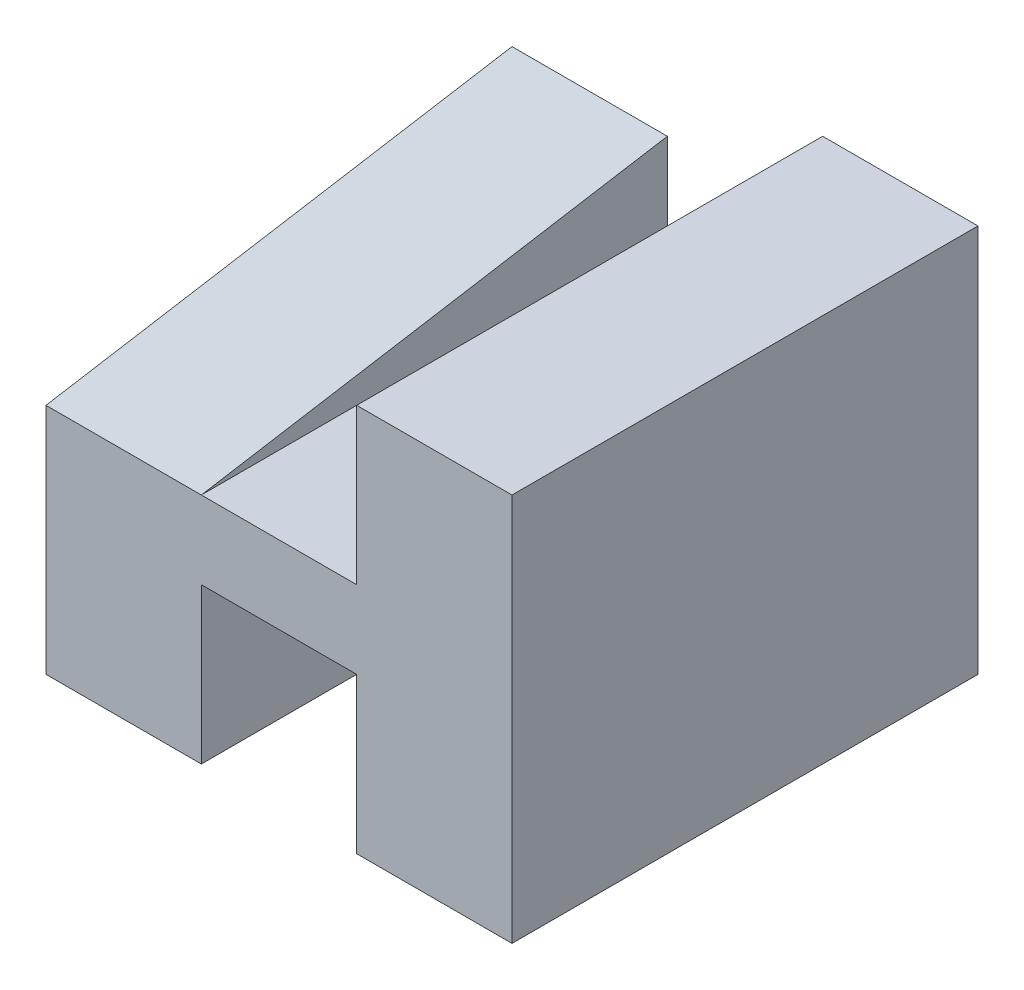
from build123d import *

# Parameters (mm, degrees)
SKETCH1_W           = 6
SKETCH1_H           = 6
BOSS_EXTRUDE1_DEPTH = 5
SKETCH2_W           = 6
SKETCH2_H           = 2
CUT_EXTRUDE1_DEPTH  = 1
CUT_EXTRUDE2_DEPTH  = 2


with BuildPart() as part:
    # Sketch1 → Boss-Extrude1 (new body)
    with BuildSketch(Plane(origin=(0, 0, 0), x_dir=(1, 0, 0), z_dir=(0, 1, 0))):
        Rectangle(SKETCH1_W, SKETCH1_H)
    extrude(amount=BOSS_EXTRUDE1_DEPTH)

    # Sketch2 → Cut-Extrude1 (cut, symmetric)
    with BuildSketch(Plane(origin=(0, 0, 0), x_dir=(0, 0, -1), z_dir=(1, 0, 0))):
        Polygon((3, 0), (-3, 2), (-3, 0), align=None)
        with Locations((0, 4)):
            Rectangle(SKETCH2_W, SKETCH2_H)
    extrude(amount=CUT_EXTRUDE1_DEPTH, both=True, mode=Mode.SUBTRACT)

    # Sketch3 → Cut-Extrude2 (cut)
    with BuildSketch(Plane.ZY.offset(3)):
        Polygon((-3, 4), (3, 3), (3, 5), (-3, 5), align=None)
    extrude(amount=-CUT_EXTRUDE2_DEPTH, mode=Mode.SUBTRACT)


solid = part.part
